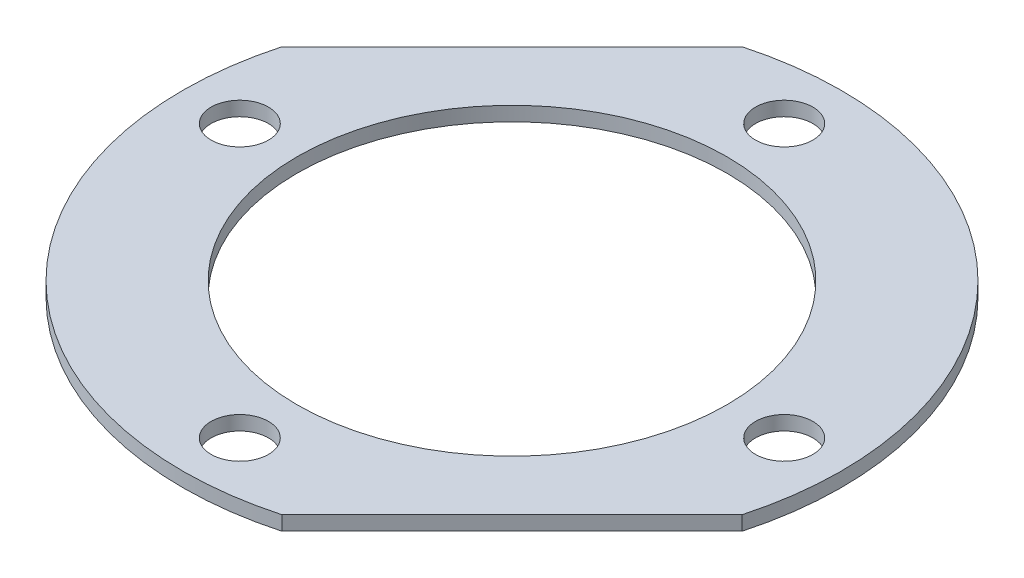
from build123d import *

# Parameters (mm, degrees)
SKETCH2_R           = 2
BOSS_EXTRUDE1_DEPTH = 1


with BuildPart() as part:
    # Sketch2 → Boss-Extrude1 (new body)
    with BuildSketch(Plane(origin=(0, 0, 0), x_dir=(1, 0, 0), z_dir=(0, 1, 0))):
        with BuildLine():
            ThreePointArc((-22.173324826, 6.110946422), (-16.263455967, -16.263455967), (6.110946422, -22.173324826))
            Line((6.110946422, -22.173324826), (22.173324826, -6.110946422))
            ThreePointArc((22.173324826, -6.110946422), (16.263455967, 16.263455967), (-6.110946422, 22.173324826))
            Line((-6.110946422, 22.173324826), (-22.173324826, 6.110946422))
        make_face()
        with BuildLine():
            ThreePointArc((0, 15), (10.606601718, 10.606601718), (15, 0))
            ThreePointArc((15, 0), (10.606601718, -10.606601718), (0, -15))
            ThreePointArc((0, -15), (-10.606601718, -10.606601718), (-15, 0))
            ThreePointArc((-15, 0), (-10.606601718, 10.606601718), (0, 15))
        make_face(mode=Mode.SUBTRACT)
        with Locations((-19, 0)):
            Circle(SKETCH2_R, mode=Mode.SUBTRACT)
        with Locations((0, 19)):
            Circle(SKETCH2_R, mode=Mode.SUBTRACT)
        with Locations((0, -19)):
            Circle(SKETCH2_R, mode=Mode.SUBTRACT)
        with Locations((19, 0)):
            Circle(SKETCH2_R, mode=Mode.SUBTRACT)
    extrude(amount=BOSS_EXTRUDE1_DEPTH)


solid = part.part
